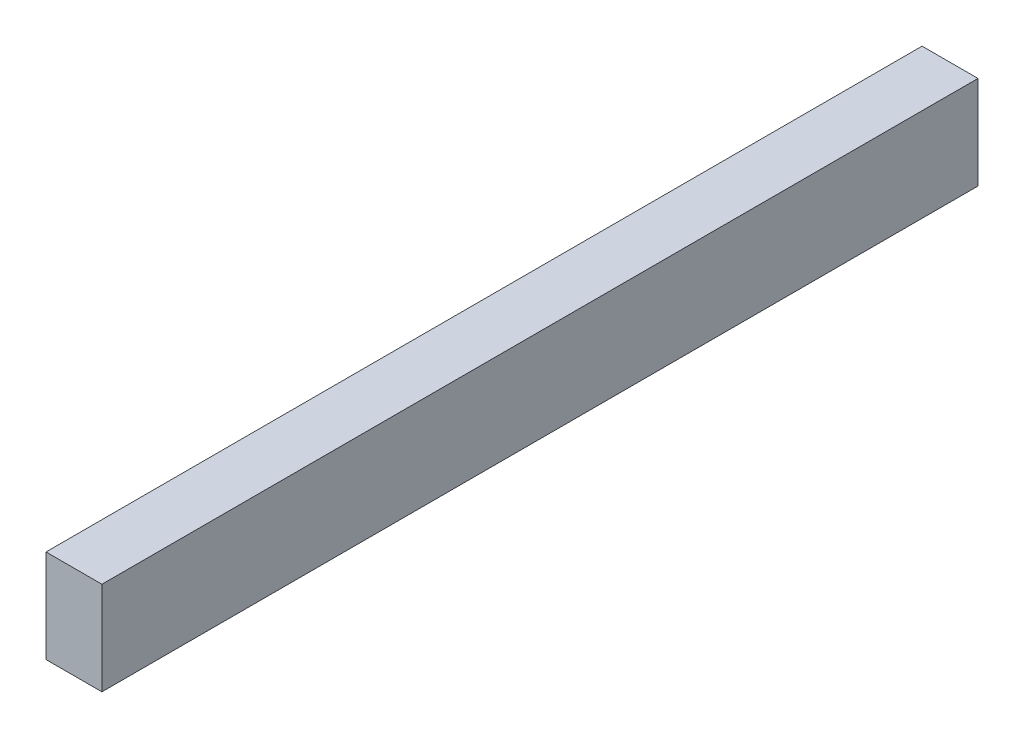
from build123d import *

# Parameters (mm, degrees)
SKETCH1_W           = 38.1
SKETCH1_H           = 63.5
BOSS_EXTRUDE1_DEPTH = 596.9


with BuildPart() as part:
    # Sketch1 → Boss-Extrude1 (new body)
    with BuildSketch(Plane.XY):
        Rectangle(SKETCH1_W, SKETCH1_H)
    extrude(amount=BOSS_EXTRUDE1_DEPTH)


solid = part.part
